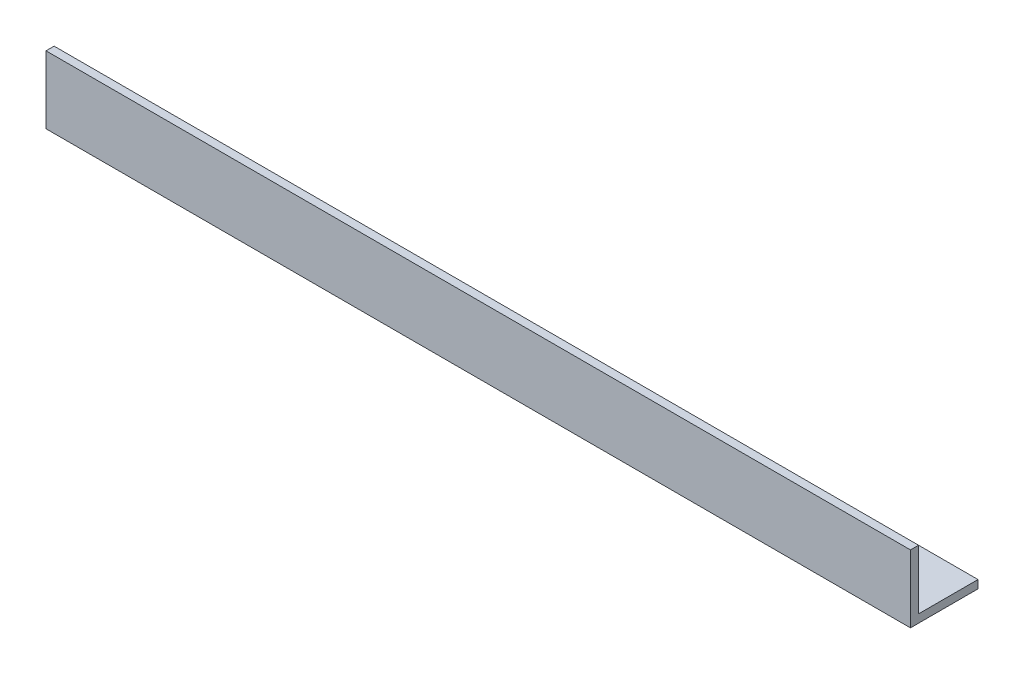
from build123d import *

# Parameters (mm, degrees)
EXTRUDE_1_DEPTH = 320


with BuildPart() as part:
    # Эскиз1 → Вытянуть-Тонкостенный1 (new body)
    with BuildSketch(Plane(origin=(0, 0, 0), x_dir=(0, 0, -1), z_dir=(1, 0, 0))):
        Polygon((0, 25), (0, 0), (25, 0), (25, 3), (3, 3), (3, 25), align=None)
    extrude(amount=EXTRUDE_1_DEPTH)


solid = part.part
